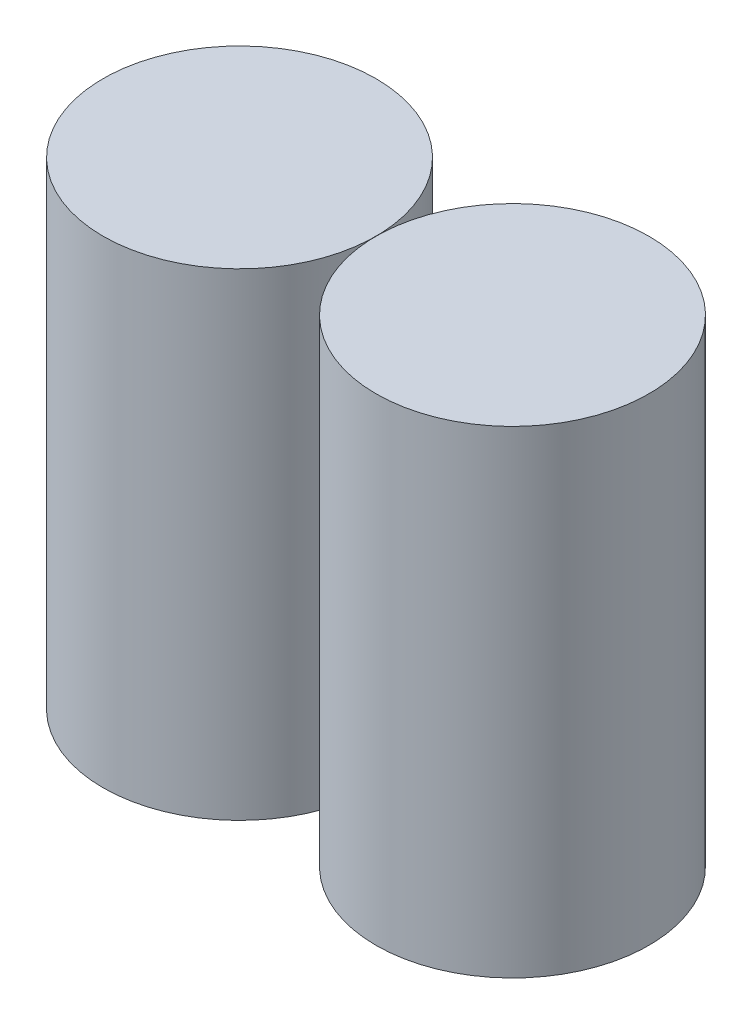
from build123d import *

# Parameters (mm, degrees)
SKETCH1_R             = 12
BOSS_EXTRUDE1_DEPTH   = 42
BOSS_EXTRUDE1_2_DEPTH = 42


with BuildPart() as part:
    # Sketch1 → Boss-Extrude1 (new body)
    with BuildSketch(Plane(origin=(0, 0, 0), x_dir=(1, 0, 0), z_dir=(0, 1, 0))):
        Circle(SKETCH1_R)
    extrude(amount=BOSS_EXTRUDE1_DEPTH)


with BuildPart() as body_2:
    # Sketch1 → Boss-Extrude1 2 (new body)
    with BuildSketch(Plane(origin=(0, 0, 0), x_dir=(1, 0, 0), z_dir=(0, 1, 0))):
        with Locations((-24, 0)):
            Circle(SKETCH1_R)
    extrude(amount=BOSS_EXTRUDE1_2_DEPTH)


solid = Compound([part.part, body_2.part])
